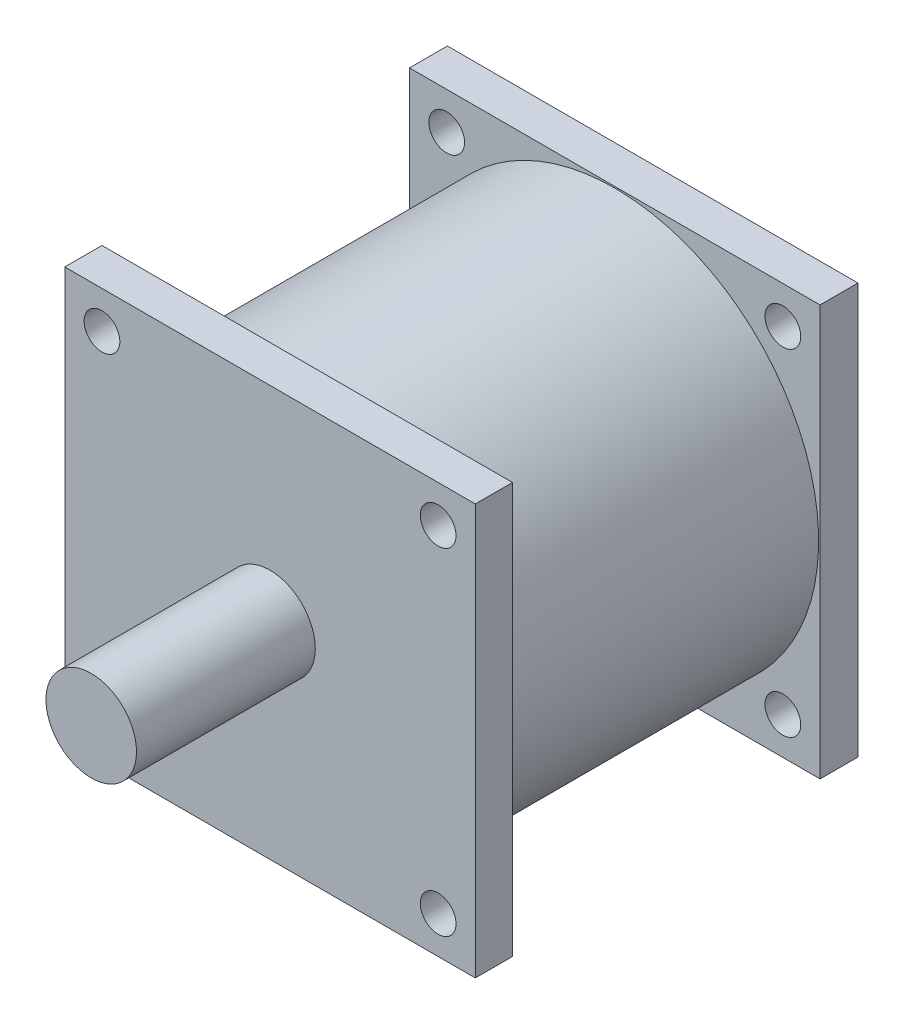
from build123d import *

# Parameters (mm, degrees)
SKIZZE1_R                       = 28.5
AUFSATZ_LINEAR_AUSTRAGEN1_DEPTH = 43
AUFSATZ_LINEAR_AUSTRAGEN2_DEPTH = 5.2
AUFSATZ_LINEAR_AUSTRAGEN3_DEPTH = 5.3
SKIZZE4_R                       = 6.33
AUFSATZ_LINEAR_AUSTRAGEN4_DEPTH = 25
M6X1_0_GEWINDEBOHRUNG1_D        = 5
M6X1_0_GEWINDEBOHRUNG1_DEPTH    = 5.2
F_5_0_5_DURCHMESSER_BOHRUNG1_D  = 5


with BuildPart() as part:
    # Skizze1 → Aufsatz-Linear austragen1 (new body)
    with BuildSketch(Plane.XY):
        Circle(SKIZZE1_R)
    extrude(amount=AUFSATZ_LINEAR_AUSTRAGEN1_DEPTH)

    # Skizze2 → Aufsatz-Linear austragen2 (add)
    with BuildSketch(Plane.XY.offset(43)):
        Polygon((28.7, 0), (28.7, 28.7), (-28.7, 28.7), (-28.7, -28.7), (28.7, -28.7), align=None)
    extrude(amount=AUFSATZ_LINEAR_AUSTRAGEN2_DEPTH)

    # Skizze3 → Aufsatz-Linear austragen3 (add)
    with BuildSketch(Plane(origin=(0, 0, 0), x_dir=(-1, 0, 0), z_dir=(0, 0, -1))):
        Polygon((28.7, 0), (28.7, 28.7), (-28.7, 28.7), (-28.7, -28.7), (28.7, -28.7), align=None)
    extrude(amount=AUFSATZ_LINEAR_AUSTRAGEN3_DEPTH)

    # Skizze4 → Aufsatz-Linear austragen4 (add)
    with BuildSketch(Plane.XY.offset(48.2)):
        Circle(SKIZZE4_R)
    extrude(amount=AUFSATZ_LINEAR_AUSTRAGEN4_DEPTH)

    # M6x1.0 Gewindebohrung1
    with Locations(Plane.XY.offset(48.2)):
        with Locations((-23.5, 23.5), (23.5, 23.5), (23.5, -23.5), (-23.5, -23.5)):
            Hole(M6X1_0_GEWINDEBOHRUNG1_D / 2, depth=M6X1_0_GEWINDEBOHRUNG1_DEPTH)

    # Ø5.0 (5) Durchmesser Bohrung1 (through all)
    with Locations(Plane.XY.offset(48.2)):
        with Locations((-23.5, 23.5), (23.5, 23.5), (23.5, -23.5), (-23.5, -23.5)):
            Hole(F_5_0_5_DURCHMESSER_BOHRUNG1_D / 2)


solid = part.part
